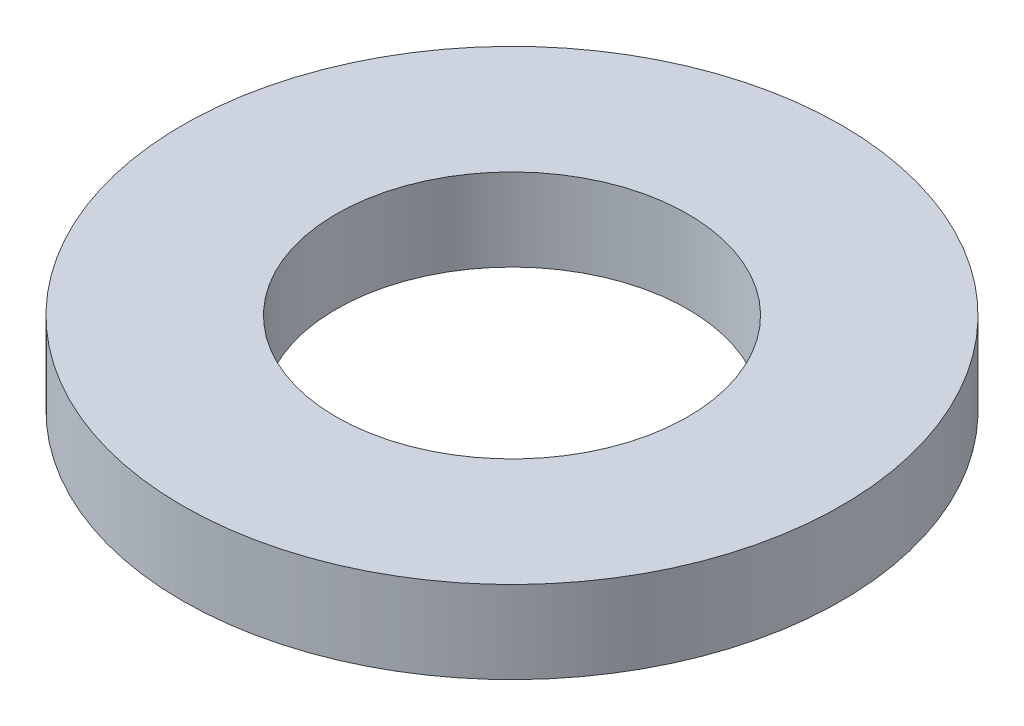
from build123d import *

# Parameters (mm, degrees)
SKETCH1_W = 2.8
SKETCH1_H = 1.5


with BuildPart() as part:
    # Sketch1 → Revolve1 (revolve)
    with BuildSketch(Plane.XY):
        with Locations((4.6, 0)):
            Rectangle(SKETCH1_W, SKETCH1_H)
    revolve(axis=Axis((0, 1.446513829, 0), (0, -1, 0)))


solid = part.part
